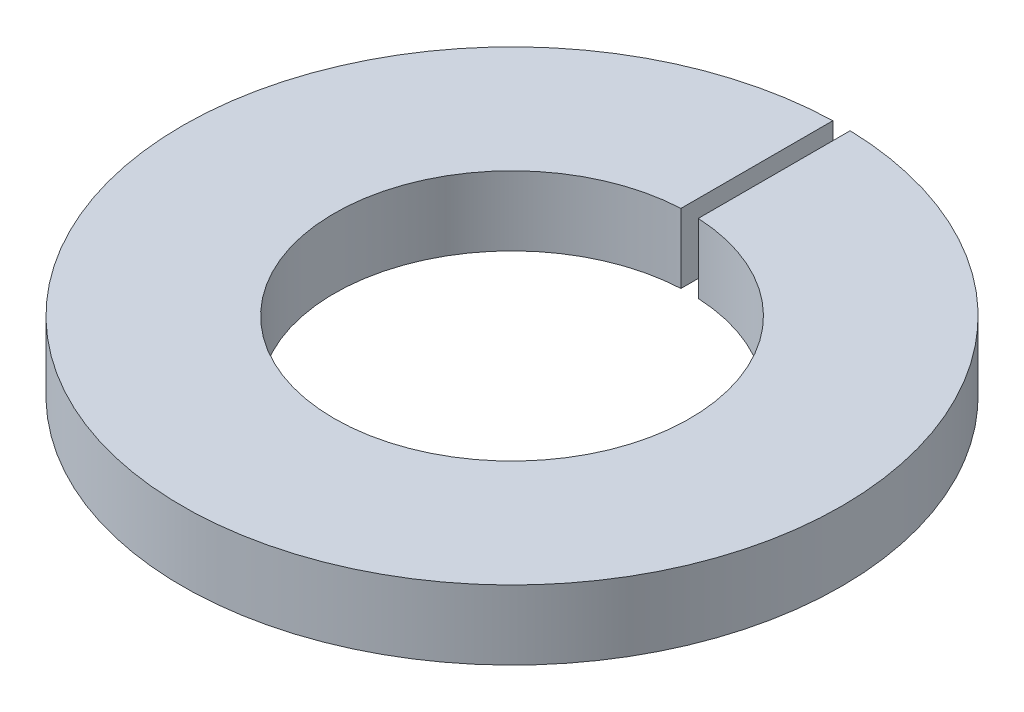
from build123d import *

# Parameters (mm, degrees)
RESSALTO_EXTRUS_O1_DEPTH = 0.8


with BuildPart() as part:
    # Esboço1 → Ressalto-extrusão1 (new body)
    with BuildSketch(Plane(origin=(0, 0, 0), x_dir=(1, 0, 0), z_dir=(0, 1, 0))):
        with BuildLine():
            Line((-0.1, 3.798683983), (-0.1, 2.047559523))
            ThreePointArc((-0.1, 2.047559523), (0, -2.05), (0.1, 2.047559523))
            Line((0.1, 2.047559523), (0.1, 3.798683983))
            ThreePointArc((0.1, 3.798683983), (0, -3.8), (-0.1, 3.798683983))
        make_face()
    extrude(amount=RESSALTO_EXTRUS_O1_DEPTH)


solid = part.part
